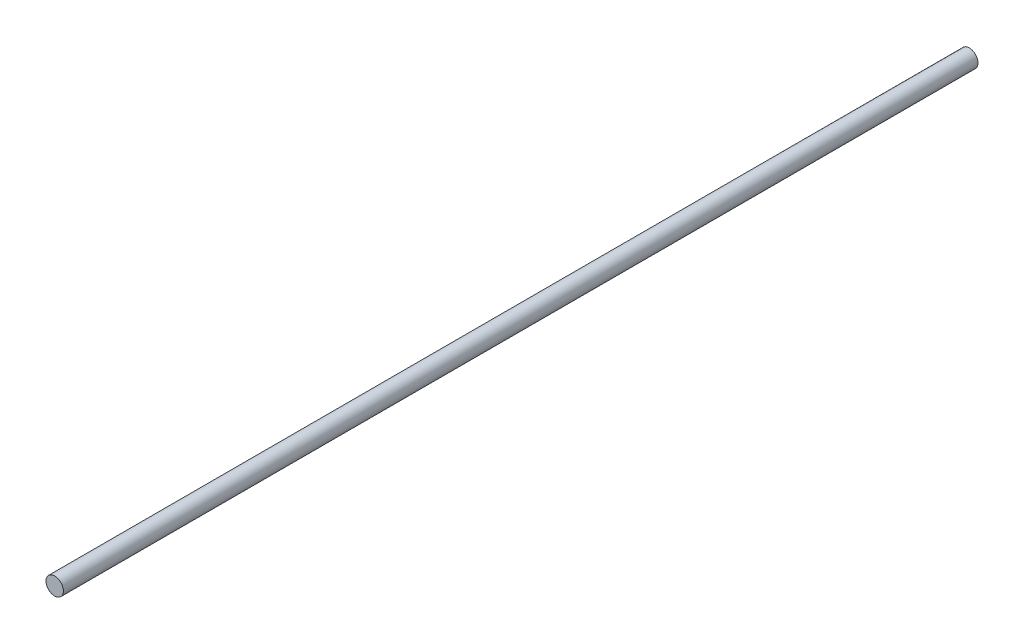
from build123d import *

# Parameters (mm, degrees)
SKETCH1_R           = 4.7625
BOSS_EXTRUDE1_DEPTH = 500


with BuildPart() as part:
    # Sketch1 → Boss-Extrude1 (new body)
    with BuildSketch(Plane.XY):
        Circle(SKETCH1_R)
    extrude(amount=BOSS_EXTRUDE1_DEPTH)


solid = part.part
